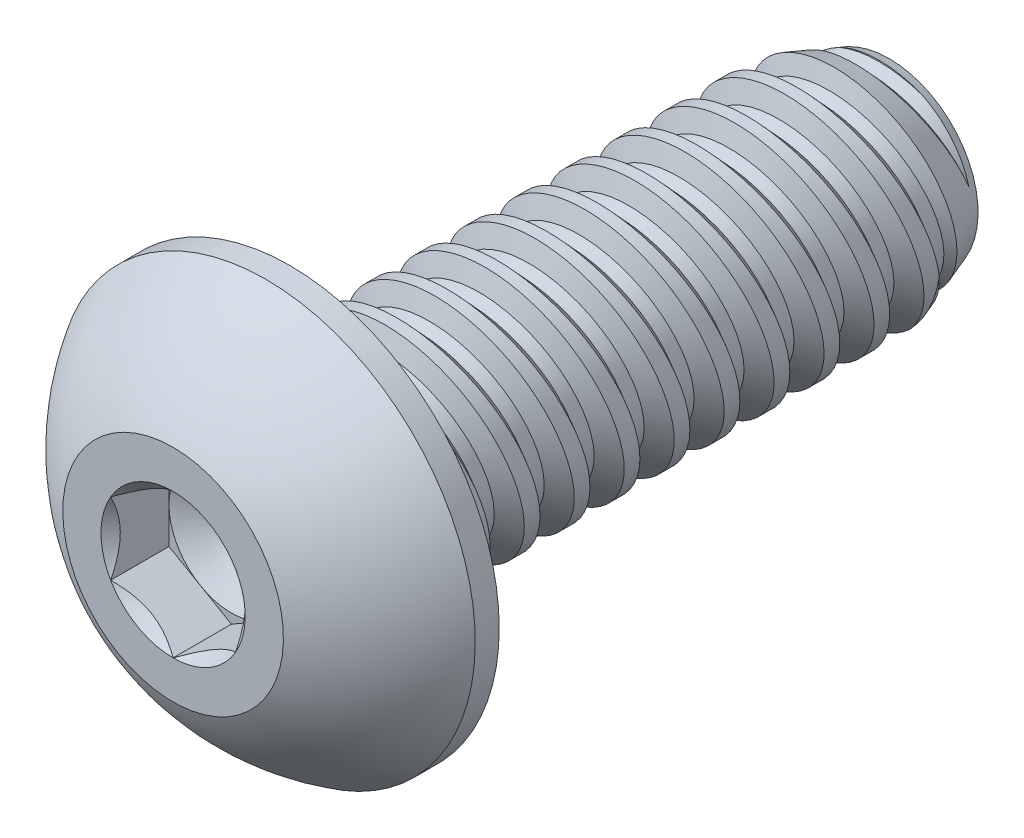
from build123d import *

# Parameters (mm, degrees)
SKETCH1_W          = 9.525
SKETCH1_H          = 1.7526
LPATTERN1_COUNT    = 12
LPATTERN1_PITCH    = 0.79375
LPATTERN2_COUNT    = 2
LPATTERN2_PITCH    = 0.79375
SKETCH4_R          = 3.3274
EXTRUDE1_DEPTH     = 1.8542
CUT_EXTRUDE1_DEPTH = 0.9271
SKETCH7_R          = 1.14567944
CUT_EXTRUDE4_DEPTH = 0.9271
CUT_EXTRUDE4_TAPER = 45
SKETCH8_R          = 0.9921875
CUT_EXTRUDE5_DEPTH = 0.309033333
CUT_EXTRUDE5_TAPER = 60


with BuildPart() as part:
    # Sketch1 → Revolve1 (revolve)
    with BuildSketch(Plane(origin=(0, 0, 0), x_dir=(0, 0, -1), z_dir=(1, 0, 0))):
        with Locations((4.7625, 0.8763)):
            Rectangle(SKETCH1_W, SKETCH1_H)
    revolve(axis=Axis((0, 0, 0), (0, 0, 1)))

    # Sketch2 → Cut-Revolve1 (revolve, cut)
    with BuildSketch(Plane(origin=(0, 0, 0), x_dir=(0, 0, -1), z_dir=(1, 0, 0))):
        Polygon((0.096768654, 1.774513192), (0.774149232, 1.927905533), (0.6271145, 1.454101991), (0.433577192, 1.410275607), align=None)
    cut_revolve1 = revolve(axis=Axis((0, -0.193538035, 0), (0, 0.220857364, -0.975306119)), mode=Mode.SUBTRACT)

    # Sketch3 → Cut-Revolve2 (revolve, cut)
    with BuildSketch(Plane(origin=(0, 0, 0), x_dir=(0, 0, -1), z_dir=(1, 0, 0))):
        Polygon((9.525, 1.410275607), (8.584471461, 1.7526), (9.525, 1.7526), align=None)
    revolve(axis=Axis((0, 0, -8.584471461), (0, 0, 1)), mode=Mode.SUBTRACT)

    # LPattern1: Cut-Revolve1 ×12
    with Locations(*[(0, 0, -i * LPATTERN1_PITCH) for i in range(1, LPATTERN1_COUNT)]):
        add(cut_revolve1, mode=Mode.SUBTRACT)

    # LPattern2: Cut-Revolve1 ×2
    with Locations(*[(0, 0, i * LPATTERN2_PITCH) for i in range(1, LPATTERN2_COUNT)]):
        add(cut_revolve1, mode=Mode.SUBTRACT)

    # Sketch4 → Extrude1 (add)
    with BuildSketch(Plane.XY):
        Circle(SKETCH4_R)
    extrude(amount=EXTRUDE1_DEPTH)

    # Sketch9 → Cut-Revolve3 (revolve, cut)
    with BuildSketch(Plane(origin=(0, 0, 0), x_dir=(0, 0, -1), z_dir=(1, 0, 0))):
        with BuildLine():
            Line((0, 3.3274), (-0.381, 3.3274))
            ThreePointArc((-0.381, 3.3274), (-1.229468441, 2.644651123), (-1.8542, 1.7526))
            Line((-1.8542, 1.7526), (-2.2352, 1.7526))
            Line((-2.2352, 1.7526), (-2.2352, 3.7084))
            Line((-2.2352, 3.7084), (0, 3.7084))
            Line((0, 3.7084), (0, 3.3274))
        make_face()
    revolve(axis=Axis((0, 0, 0), (0, 0, 1)), mode=Mode.SUBTRACT)

    # Sketch6 → Cut-Extrude1 (cut)
    with BuildSketch(Plane.XY.offset(1.8542)):
        Polygon((0, -1.14567944), (0.9921875, -0.57283972), (0.9921875, 0.57283972), (0, 1.14567944), (-0.9921875, 0.57283972), (-0.9921875, -0.57283972), align=None)
    extrude(amount=-CUT_EXTRUDE1_DEPTH, mode=Mode.SUBTRACT)

    # Sketch7 → Cut-Extrude4 (cut)
    with BuildSketch(Plane.XY.offset(1.8542)):
        Circle(SKETCH7_R)
    extrude(amount=-CUT_EXTRUDE4_DEPTH, taper=CUT_EXTRUDE4_TAPER, mode=Mode.SUBTRACT)

    # Sketch8 → Cut-Extrude5 (cut)
    with BuildSketch(Plane.XY.offset(0.9271)):
        Circle(SKETCH8_R)
    extrude(amount=-CUT_EXTRUDE5_DEPTH, taper=CUT_EXTRUDE5_TAPER, mode=Mode.SUBTRACT)


solid = part.part
